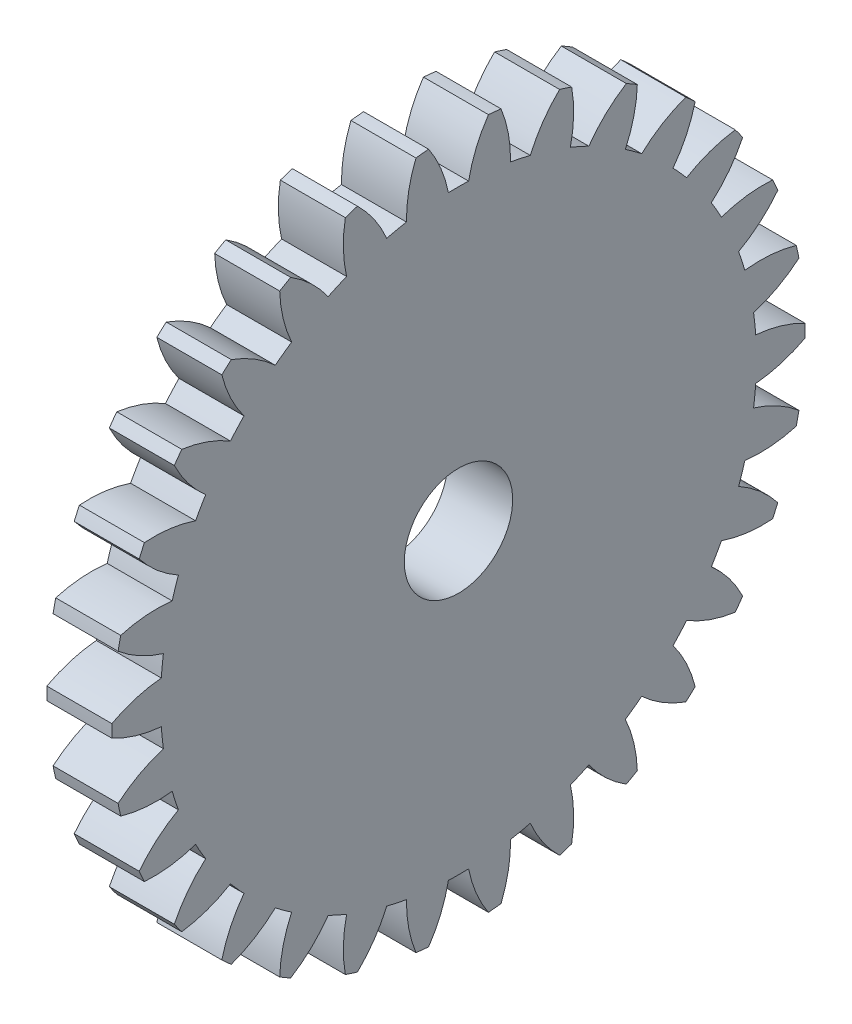
from build123d import *

# Parameters (mm, degrees)
BASPROSKE_W     = 3
BASPROSKE_H     = 16
TOOTHCUT_DEPTH  = 23.825424421
TEETHCUTS_COUNT = 30
TEETHCUTS_ANGLE = 348
BORSKE_R        = 2.5
BORE_DEPTH      = 50.0000508


with BuildPart() as part:
    # BasProSke → Base-Revolve (revolve)
    with BuildSketch(Plane(origin=(0, 0, 0), x_dir=(1, 0, 0), z_dir=(0, 1, 0)), mode=Mode.PRIVATE) as base_revolve_sk:
        with Locations((1.5, 8)):
            Rectangle(BASPROSKE_W, BASPROSKE_H)
    revolve(base_revolve_sk.sketch.rotate(Axis((-10, 0, 0), (1, 0, 0)), 180), axis=Axis((-10, 0, 0), (1, 0, 0)))

    # TooCutSke → ToothCut (cut, through all)
    with BuildSketch(Plane(origin=(0, 0, 0), x_dir=(0, 0, -1), z_dir=(1, 0, 0))):
        with BuildLine():
            ThreePointArc((0.466400716, 13.741086979), (0, 13.749), (-0.466400716, 13.741086979))
            ThreePointArc((-0.466400716, 13.741086979), (-0.819142092, 14.899954875), (-1.3974676, 15.964351834))
            ThreePointArc((-1.3974676, 15.964351834), (0, 16.0254), (1.3974676, 15.964351834))
            ThreePointArc((1.3974676, 15.964351834), (0.819142092, 14.899954875), (0.466400716, 13.741086979))
        make_face()
    toothcut = extrude(amount=TOOTHCUT_DEPTH, mode=Mode.SUBTRACT)

    # TeethCuts: ToothCut ×30 about axis
    teethcuts_axis = Axis((-10, 0, 0), (1, 0, 0))
    for i in range(1, TEETHCUTS_COUNT):
        add(toothcut.rotate(teethcuts_axis, i * TEETHCUTS_ANGLE / (TEETHCUTS_COUNT - 1)), mode=Mode.SUBTRACT)

    # BorSke → Bore (cut, symmetric)
    with BuildSketch(Plane(origin=(0, 0, 0), x_dir=(0, 0, -1), z_dir=(1, 0, 0))):
        with Locations(Location((0, 0, 0), (0, 0, 180))):
            Circle(BORSKE_R)
    extrude(amount=BORE_DEPTH, both=True, mode=Mode.SUBTRACT)


solid = part.part
